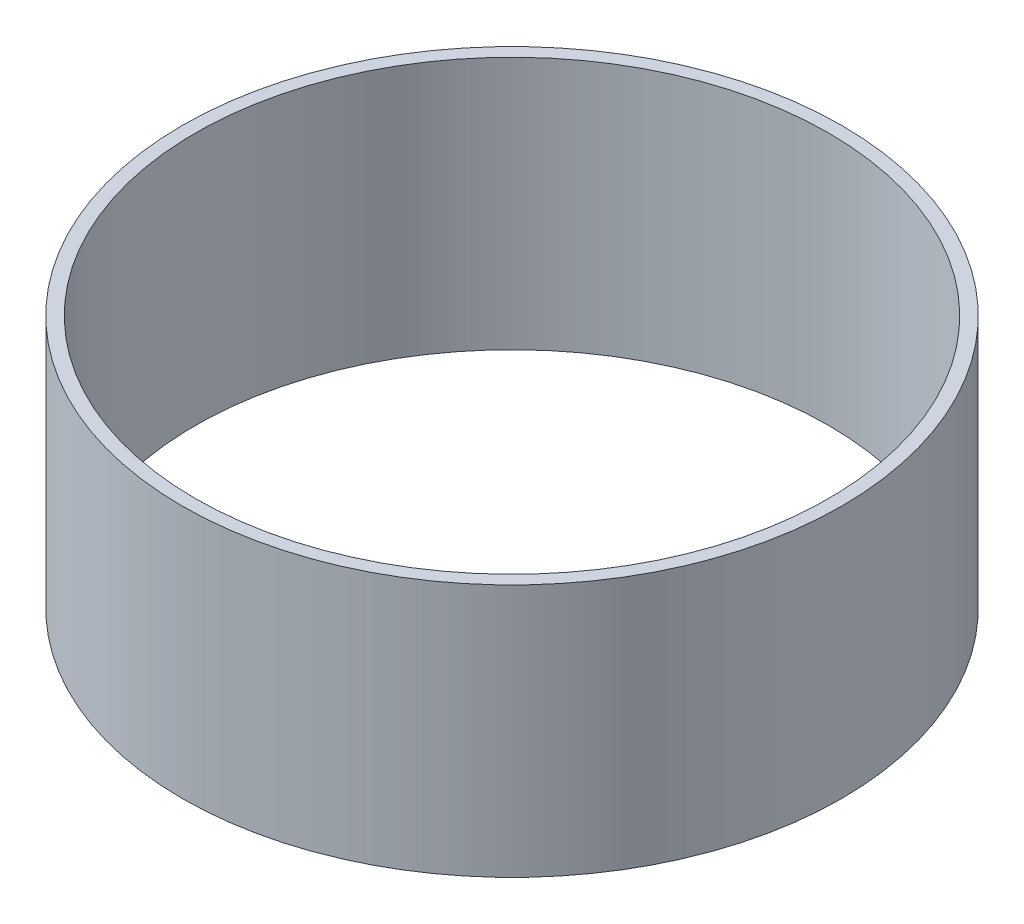
from build123d import *

# Parameters (mm, degrees)
SKETCH1_R           = 39.6748
SKETCH1_R_2         = 38.1
BOSS_EXTRUDE1_DEPTH = 15.24


with BuildPart() as part:
    # Sketch1 → Boss-Extrude1 (new body, symmetric)
    with BuildSketch(Plane(origin=(0, 0, 0), x_dir=(1, 0, 0), z_dir=(0, 1, 0))):
        Circle(SKETCH1_R)
        Circle(SKETCH1_R_2, mode=Mode.SUBTRACT)
    extrude(amount=BOSS_EXTRUDE1_DEPTH, both=True)


solid = part.part
